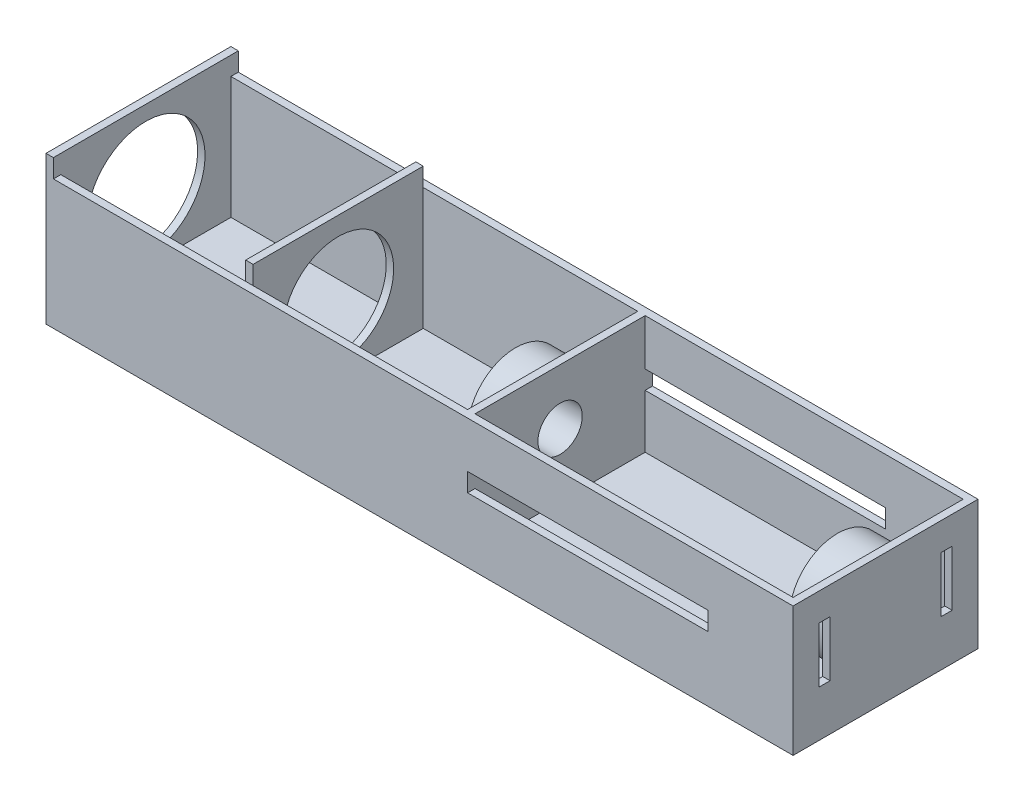
from build123d import *

# Parameters (mm, degrees)
SKETCH_1_W          = 90
SKETCH_1_H          = 50
EXTRUDE_1_DEPTH     = 35
SKETCH_2_W          = 86
SKETCH_2_H          = 46
CUT_EXTRUDE_1_DEPTH = 32
SKETCH_3_R          = 6
CUT_EXTRUDE_2_DEPTH = 2
SKETCH_4_R          = 13
SKETCH_4_R_2        = 6
EXTRUDE_2_DEPTH     = 11
SKETCH_5_R          = 13
SKETCH_5_R_2        = 6
EXTRUDE_4_DEPTH     = 12
SKETCH_6_W          = 65
SKETCH_6_H          = 5
CUT_EXTRUDE_3_DEPTH = 51
SKETCH_7_W          = 3
SKETCH_7_H          = 15
CUT_EXTRUDE_4_DEPTH = 30
EXTRUDE_5_DEPTH     = 110
SKETCH_9_W          = 50
SKETCH_9_H          = 40
SKETCH_9_R          = 16
EXTRUDE_6_DEPTH     = 2
SKETCH_10_W         = 2
SKETCH_10_H         = 46
EXTRUDE_7_DEPTH     = 38
SKETCH_11_R         = 15
CUT_EXTRUDE_5_DEPTH = 10


with BuildPart() as part:
    # 草圖1 → 填料-伸長1 (new body)
    with BuildSketch(Plane(origin=(0, 0, 0), x_dir=(1, 0, 0), z_dir=(0, 1, 0))):
        Rectangle(SKETCH_1_W, SKETCH_1_H)
    extrude(amount=EXTRUDE_1_DEPTH)

    # 草圖2 → 除料-伸長1 (cut)
    with BuildSketch(Plane(origin=(0, 35, 0), x_dir=(1, 0, 0), z_dir=(0, 1, 0))):
        Rectangle(SKETCH_2_W, SKETCH_2_H)
    extrude(amount=-CUT_EXTRUDE_1_DEPTH, mode=Mode.SUBTRACT)

    # 草圖3 → 除料-伸長2 (cut)
    with BuildSketch(Plane.ZY.offset(45)):
        with Locations((0, 20)):
            Circle(SKETCH_3_R)
    extrude(amount=-CUT_EXTRUDE_2_DEPTH, mode=Mode.SUBTRACT)

    # 草圖4 → 填料-伸長2 (add)
    with BuildSketch(Plane.ZY.offset(-43)):
        with Locations((0, 20)):
            Circle(SKETCH_4_R)
        with Locations((0, 20)):
            Circle(SKETCH_4_R_2, mode=Mode.SUBTRACT)
    extrude(amount=EXTRUDE_2_DEPTH)

    # 草圖5 → 填料-伸長4 (add)
    with BuildSketch(Plane(origin=(-43, 0, 0), x_dir=(0, 0, -1), z_dir=(1, 0, 0))):
        with Locations((0, 20)):
            Circle(SKETCH_5_R)
        with Locations((0, 20)):
            Circle(SKETCH_5_R_2, mode=Mode.SUBTRACT)
    extrude(amount=-EXTRUDE_4_DEPTH)

    # 草圖6 → 除料-伸長3 (cut, through all)
    with BuildSketch(Plane(origin=(0, 0, -25), x_dir=(-1, 0, 0), z_dir=(0, 0, -1))):
        with Locations((10.5, 20)):
            Rectangle(SKETCH_6_W, SKETCH_6_H)
    extrude(amount=-CUT_EXTRUDE_3_DEPTH, mode=Mode.SUBTRACT)

    # 草圖7 → 除料-伸長4 (cut)
    with BuildSketch(Plane(origin=(45, 0, 0), x_dir=(0, 0, -1), z_dir=(1, 0, 0))):
        with Locations((-16.5, 20)):
            Rectangle(SKETCH_7_W, SKETCH_7_H)
        with Locations((16.5, 20)):
            Rectangle(SKETCH_7_W, SKETCH_7_H)
    extrude(amount=-CUT_EXTRUDE_4_DEPTH, mode=Mode.SUBTRACT)

    # 草圖8 → 填料-伸長5 (add)
    with BuildSketch(Plane.ZY.offset(45)):
        Polygon((-25, 35), (-23, 35), (-23, 2), (23, 2), (23, 35), (25, 35), (25, 0), (23, 0), (-23, 0), (-25, 0), align=None)
    extrude(amount=EXTRUDE_5_DEPTH)

    # 草圖9 → 填料-伸長6 (add)
    with BuildSketch(Plane.ZY.offset(155)):
        with Locations((0, 20)):
            Rectangle(SKETCH_9_W, SKETCH_9_H)
        with Locations((0, 20)):
            Circle(SKETCH_9_R, mode=Mode.SUBTRACT)
    extrude(amount=EXTRUDE_6_DEPTH)

    # 草圖10 → 填料-伸長7 (add)
    with BuildSketch(Plane(origin=(0, 2, 0), x_dir=(1, 0, 0), z_dir=(0, 1, 0))):
        with Locations((-104, 0)):
            Rectangle(SKETCH_10_W, SKETCH_10_H)
    extrude(amount=EXTRUDE_7_DEPTH)

    # 草圖11 → 除料-伸長5 (cut)
    with BuildSketch(Plane.ZY.offset(105)):
        with Locations((0, 20)):
            Circle(SKETCH_11_R)
    extrude(amount=-CUT_EXTRUDE_5_DEPTH, mode=Mode.SUBTRACT)


solid = part.part
